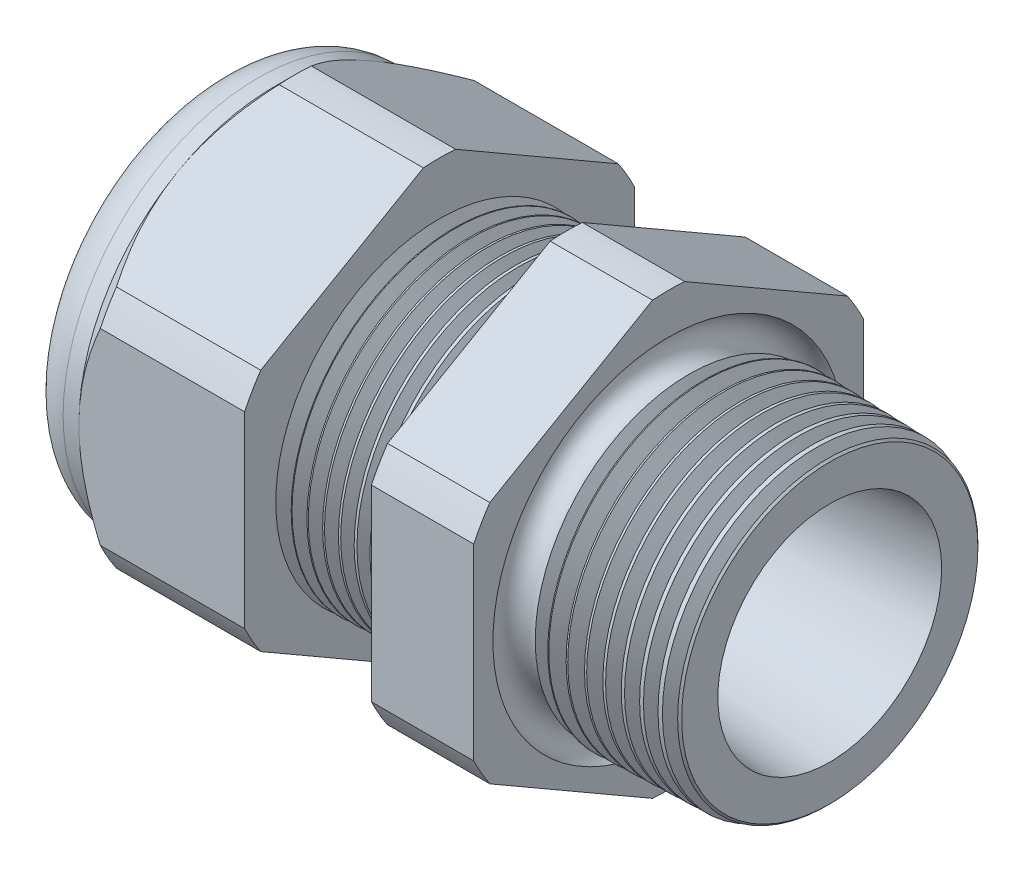
from build123d import *

# Parameters (mm, degrees)
SKETCH12_OUTSIDE_W = 52.432
SKETCH12_OUTSIDE_H = 52.432
CUT_EXTRUDE2_DEPTH = 28.172
FILLET4_R          = 2.032
SKETCH19_OUTSIDE_W = 33.316
SKETCH19_OUTSIDE_H = 35.412
SKETCH19_OUTSIDE_R = 9.525
CUT_EXTRUDE3_DEPTH = 1.999996
CUT_EXTRUDE3_DRAFT = -45
CHAMFER1_SIZE      = 0.260919487
CHAMFER1_SIZE2     = 0.254
SKETCH21_R         = 3.937
PLUG_DEPTH         = 3.81
SKETCH22_R         = 3.683
CUT_EXTRUDE4_DEPTH = 0.508
SKETCH27_R         = 1.143
PLUGHOLES_DEPTH    = 30.464
CIRPATTERN1_COUNT  = 4
LPATTERN1_COUNT    = 8
LPATTERN1_PITCH    = 0.762
LPATTERN2_COUNT    = 9
LPATTERN2_PITCH    = 0.889
SKETCH32_R         = 0.889


with BuildPart() as part:
    # Sketch10 → Revolve2 (revolve)
    with BuildSketch(Plane.XY, mode=Mode.PRIVATE) as revolve2_sk:
        Polygon((-29.972, 3.937), (-19.072, 3.937), (0, 5.469582104), (0, 7.501582104), (-7.874, 7.70777005), (-7.874, 19.05), (-12.874, 19.05), (-12.874, 7.838699658), (-19.072, 8.001), (-19.072, 19.05), (-27.172, 19.05), (-27.172, 9.525), (-29.972, 9.525), align=None)
    revolve(revolve2_sk.sketch.rotate(Axis((0, 0, 0), (-1, 0, 0)), 90), axis=Axis((0, 0, 0), (-1, 0, 0)))  # turned: the seam where the file's is

    # Sketch12 outside → Cut-Extrude2 (cut, through all)
    with BuildSketch(Plane.ZY.offset(27.172)):
        Rectangle(SKETCH12_OUTSIDE_W, SKETCH12_OUTSIDE_H)
        with BuildLine():
            Line((-0.788451287, 10.543310065), (-8.736548713, 5.954473877))
            ThreePointArc((-8.736548713, 5.954473877), (-9.156270088, 5.286375), (-9.525, 4.588836188))
            Line((-9.525, 4.588836188), (-9.525, -4.588836188))
            ThreePointArc((-9.525, -4.588836188), (-9.156270088, -5.286375), (-8.736548713, -5.954473877))
            Line((-8.736548713, -5.954473877), (-0.788451287, -10.543310065))
            ThreePointArc((-0.788451287, -10.543310065), (0, -10.57275), (0.788451287, -10.543310065))
            Line((0.788451287, -10.543310065), (8.736548713, -5.954473877))
            ThreePointArc((8.736548713, -5.954473877), (9.156270088, -5.286375), (9.525, -4.588836188))
            Line((9.525, -4.588836188), (9.525, 4.588836188))
            ThreePointArc((9.525, 4.588836188), (9.156270088, 5.286375), (8.736548713, 5.954473877))
            Line((8.736548713, 5.954473877), (0.788451287, 10.543310065))
            ThreePointArc((0.788451287, 10.543310065), (0, 10.57275), (-0.788451287, 10.543310065))
        make_face(mode=Mode.SUBTRACT)
    extrude(amount=-CUT_EXTRUDE2_DEPTH, mode=Mode.SUBTRACT)

    # Fillet4
    fillet4_edges = [part.edges().sort_by_distance(p)[0] for p in [
        (-29.972, 0, 9.525),
    ]]
    fillet(fillet4_edges, radius=FILLET4_R)


with BuildPart() as cut_extrude3_tool:
    # Sketch19 outside → Cut-Extrude3 (with draft: the straight prism first)
    with BuildSketch(Plane.ZY.offset(27.172)):
        Rectangle(SKETCH19_OUTSIDE_W, SKETCH19_OUTSIDE_H)
        Circle(SKETCH19_OUTSIDE_R, mode=Mode.SUBTRACT)
    extrude(amount=-CUT_EXTRUDE3_DEPTH)
    # Cut-Extrude3: the draft: its side faces are tilted about the plane it starts from
    cut_extrude3_sides = [cut_extrude3_tool.faces().sort_by_distance(p)[0] for p in [
        (-26.172002, -17.706, 0),
        (-26.172002, 0, 16.658),
        (-26.172002, 17.706, 0),
        (-26.172002, 0, -16.658),
        (-26.172002, 0, -9.525),
    ]]
    draft(cut_extrude3_sides, Plane.ZY.offset(27.172), CUT_EXTRUDE3_DRAFT)


with BuildPart() as part_1:
    add(part.part)

    # Cut-Extrude3: cut by cut_extrude3_tool
    add(cut_extrude3_tool.part, mode=Mode.SUBTRACT)

    # Chamfer1
    chamfer1_edges = [part_1.edges().sort_by_distance(p)[0] for p in [
        (0, 0, 7.501582104),
    ]]
    chamfer1_side = [part_1.faces().sort_by_distance(p)[0] for p in [
        (0, 0, 5.681758887),
    ]]
    chamfer(chamfer1_edges, length=CHAMFER1_SIZE, length2=CHAMFER1_SIZE2, reference=chamfer1_side[0])

    # Sketch29 → Cut-Revolve1 (revolve, cut)
    with BuildSketch(Plane.XY, mode=Mode.PRIVATE) as cut_revolve1_sk:
        Polygon((-19.072, 8.001), (-18.339016419, 7.981806149), (-18.722130572, 7.356620673), align=None)
    cut_revolve1 = revolve(cut_revolve1_sk.sketch.rotate(Axis((0, 0, 0), (-1, 0, 0)), 90), axis=Axis((0, 0, 0), (-1, 0, 0)), mode=Mode.SUBTRACT)  # turned: the seam where the file's is

    # LPattern1: Cut-Revolve1 ×8
    with Locations(*[(i * LPATTERN1_PITCH, 0, 0) for i in range(1, LPATTERN1_COUNT)]):
        add(cut_revolve1, mode=Mode.SUBTRACT)

    # Sketch30 → Cut-Revolve2 (revolve, cut)
    with BuildSketch(Plane.XY, mode=Mode.PRIVATE) as cut_revolve2_sk:
        Polygon((-7.874, 7.70777005), (-6.994419703, 7.68473743), (-7.454156686, 6.934514858), align=None)
    cut_revolve2 = revolve(cut_revolve2_sk.sketch.rotate(Axis((0, 0, 0), (-1, 0, 0)), 270), axis=Axis((0, 0, 0), (-1, 0, 0)), mode=Mode.SUBTRACT)  # turned: the seam where the file's is

    # LPattern2: Cut-Revolve2 ×9
    with Locations(*[(i * LPATTERN2_PITCH, 0, 0) for i in range(1, LPATTERN2_COUNT)]):
        add(cut_revolve2, mode=Mode.SUBTRACT)

    # Sketch32 → Cut-Revolve3 (revolve, cut)
    with BuildSketch(Plane.XY, mode=Mode.PRIVATE) as cut_revolve3_sk:
        with Locations((-7.747, 7.70777005)):
            Circle(SKETCH32_R)
    revolve(cut_revolve3_sk.sketch.rotate(Axis((0, 0, 0), (-1, 0, 0)), 270), axis=Axis((0, 0, 0), (-1, 0, 0)), mode=Mode.SUBTRACT)  # turned: the seam where the file's is


with BuildPart() as body_2:
    # Sketch21 → plug (new body)
    with BuildSketch(Plane.ZY.offset(29.972)):
        Circle(SKETCH21_R)
    extrude(amount=-PLUG_DEPTH)

    # Sketch22 → Cut-Extrude4 (cut)
    with BuildSketch(Plane.ZY.offset(29.972)):
        Circle(SKETCH22_R)
    extrude(amount=-CUT_EXTRUDE4_DEPTH, mode=Mode.SUBTRACT)

    # Sketch27 → plugholes (cut, through all)
    with BuildSketch(Plane.ZY.offset(29.464)):
        with Locations((-2.535428, 0)):
            Circle(SKETCH27_R)
    plugholes = extrude(amount=-PLUGHOLES_DEPTH, mode=Mode.SUBTRACT)

    # CirPattern1: plugholes ×4 about axis
    cirpattern1_axis = Axis((0, 0, 0), (1, 0, 0))
    for i in range(1, CIRPATTERN1_COUNT):
        add(plugholes.rotate(cirpattern1_axis, i * 360 / CIRPATTERN1_COUNT), mode=Mode.SUBTRACT)


solid = Compound([part_1.part, body_2.part])
